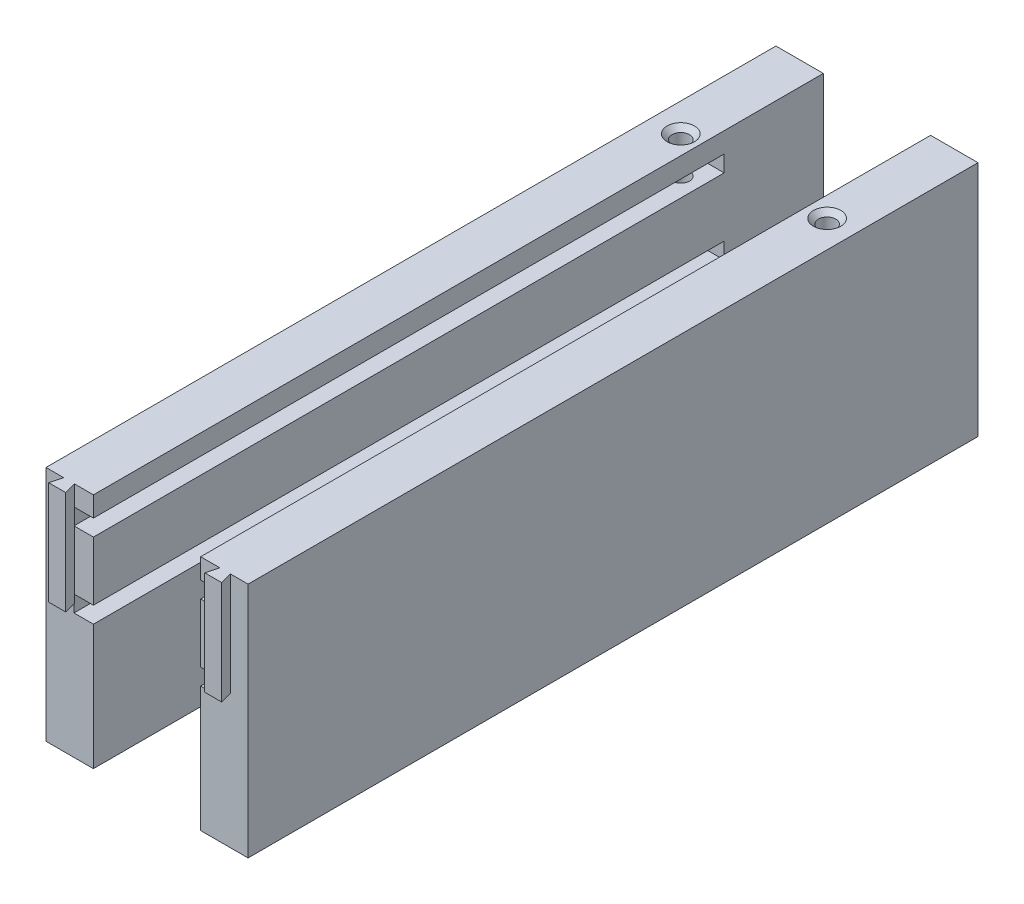
from build123d import *

# Parameters (mm, degrees)
SKETCH1_W                      = 147
SKETCH1_H                      = 47
BOSS_EXTRUDE1_DEPTH            = 8
CUT_EXTRUDE8_DEPTH             = 25
SKETCH43_W                     = 5
SKETCH43_H                     = 15
BOSS_EXTRUDE8_DEPTH            = 6
SKETCH44_W                     = 15
SKETCH44_H                     = 11
BOSS_EXTRUDE9_DEPTH            = 6
SKETCH13_W                     = 12
SKETCH13_H                     = 2.35
CUT_EXTRUDE9_DEPTH             = 26.5
SKETCH46_W                     = 3.85
SKETCH46_H                     = 3.25
CUT_EXTRUDE15_DEPTH            = 125
SKETCH47_W                     = 1.397180602
SKETCH47_H                     = 144.65
BOSS_EXTRUDE10_DEPTH           = 47
F_8_32_TAPPED_HOLE1_AT_2_COUNT = 2
F_8_32_TAPPED_HOLE1_AT_2_PITCH = 29


with BuildPart() as part:
    # Sketch1 → Boss-Extrude1 (new body)
    with BuildSketch(Plane(origin=(0, 0, 0), x_dir=(0, 0, -1), z_dir=(1, 0, 0))):
        with Locations((8.695219221, -9.320528122)):
            Rectangle(SKETCH1_W, SKETCH1_H)
    extrude(amount=BOSS_EXTRUDE1_DEPTH)

    # Sketch12 → Cut-Extrude8 (cut)
    with BuildSketch(Plane(origin=(0, 14.179471878, 0), x_dir=(1, 0, 0), z_dir=(0, 1, 0))):
        Polygon((0, -62.454780779), (2.109680602, -62.454780779), (1.48, -64.804780779), (0, -64.804780779), align=None)
        Polygon((8, -62.454780779), (8, -64.804780779), (4.839361204, -64.804780779), (4.209680602, -62.454780779), align=None)
    extrude(amount=-CUT_EXTRUDE8_DEPTH, mode=Mode.SUBTRACT)

    # Sketch43 → Boss-Extrude8 (add)
    with BuildSketch(Plane(origin=(8, 0, 0), x_dir=(0, 0, -1), z_dir=(1, 0, 0))):
        with Locations((74.695219221, -15.320528122)):
            Rectangle(SKETCH43_W, SKETCH43_H)
    extrude(amount=BOSS_EXTRUDE8_DEPTH)

    # Sketch44 → Boss-Extrude9 (add)
    with BuildSketch(Plane(origin=(8, 0, 0), x_dir=(0, 0, -1), z_dir=(1, 0, 0))):
        with Locations((59.695219221, -27.320528122)):
            Rectangle(SKETCH44_W, SKETCH44_H)
    extrude(amount=BOSS_EXTRUDE9_DEPTH)

    # Sketch13 → Cut-Extrude9 (cut)
    with BuildSketch(Plane.XZ.offset(32.820528122)):
        with Locations((4.084013989, 63.629780779)):
            Rectangle(SKETCH13_W, SKETCH13_H)
    extrude(amount=-CUT_EXTRUDE9_DEPTH, mode=Mode.SUBTRACT)

    # Sketch46 → Cut-Extrude15 (cut)
    with BuildSketch(Plane.XY.offset(62.454780779)):
        with Locations((6.075, 8.554471878)):
            Rectangle(SKETCH46_W, SKETCH46_H)
        with Locations((6.075, -6.395528122)):
            Rectangle(SKETCH46_W, SKETCH46_H)
    extrude(amount=-CUT_EXTRUDE15_DEPTH, mode=Mode.SUBTRACT)

    # Sketch47 → Boss-Extrude10 (add)
    with BuildSketch(Plane(origin=(0, 14.179471878, 0), x_dir=(1, 0, 0), z_dir=(0, 1, 0))):
        with Locations((-0.698590301, 9.870219221)):
            Rectangle(SKETCH47_W, SKETCH47_H)
    extrude(amount=-BOSS_EXTRUDE10_DEPTH)


with BuildPart() as body_2:
    # Mirror4: mirrored copy
    add(part.part.mirror(Plane.ZY.offset(-18.625)))

    # Sketch37 → #8-32 Tapped Hole1 (revolve, cut)
    with BuildSketch(Plane(origin=(33.25, 14.179471878, -57.695219221), x_dir=(0, 0, 1), z_dir=(1, 0, 0))):
        Polygon((0, 0), (0, 10.70744), (1.7272, 9.669633539), (1.7272, 0.9906), (2.7178, 0), align=None)
    f_8_32_tapped_hole1 = revolve(axis=Axis((33.25, 20.529471878, -57.695219221), (0, -1, 0)), mode=Mode.SUBTRACT)


with BuildPart() as part_1:
    add(part.part)

    # #8-32 Tapped Hole1 at 2: #8-32 Tapped Hole1 ×2
    with Locations(*[(-i * F_8_32_TAPPED_HOLE1_AT_2_PITCH, 0, 0) for i in range(1, F_8_32_TAPPED_HOLE1_AT_2_COUNT)]):
        add(f_8_32_tapped_hole1, mode=Mode.SUBTRACT)


solid = Compound([body_2.part, part_1.part])
